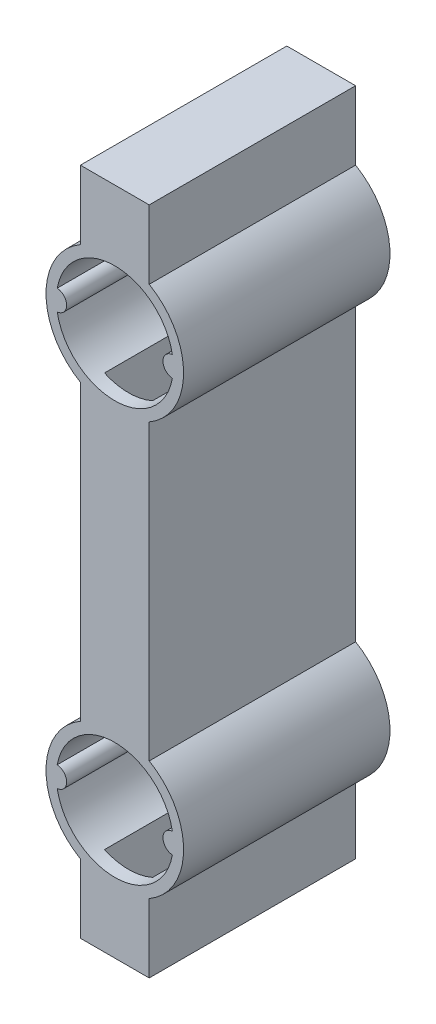
from build123d import *
from build123d.topology import SkipClean

# Parameters (mm, degrees)
BOSS_EXTRU_1_DEPTH      = 30
ENL_V_MAT_EXTRU_1_DEPTH = 28
BOSS_EXTRU_2_DEPTH      = 2
ESQUISSE5_R             = 2.5
ENL_V_MAT_EXTRU_2_DEPTH = 2
BOSS_EXTRU_3_DEPTH      = 29
ENL_V_MAT_EXTRU_4_DEPTH = 29
BOSS_EXTRU_4_DEPTH      = 28


with BuildPart() as part:
    # Esquisse1 → Boss.-Extru.1 (new body)
    with BuildSketch(Plane.XY):
        with BuildLine():
            Line((-5, -21.339745962), (-5, 21.339745962))
            ThreePointArc((-5, 21.339745962), (-10, 30), (-5, 38.660254038))
            Line((-5, 38.660254038), (-5, 48.660254038))
            Line((-5, 48.660254038), (5, 48.660254038))
            Line((5, 48.660254038), (5, 38.660254038))
            ThreePointArc((5, 38.660254038), (10, 30), (5, 21.339745962))
            Line((5, 21.339745962), (5, -21.339745962))
            ThreePointArc((5, -21.339745962), (10, -30), (5, -38.660254038))
            Line((5, -38.660254038), (5, -48.660254038))
            Line((5, -48.660254038), (-5, -48.660254038))
            Line((-5, -48.660254038), (-5, -38.660254038))
            ThreePointArc((-5, -38.660254038), (-10, -30), (-5, -21.339745962))
        make_face()
    extrude(amount=BOSS_EXTRU_1_DEPTH)

    # Esquisse2 → Enl_v. mat.-Extru.1 (cut)
    with BuildSketch(Plane.XY.offset(30)):
        with BuildLine():
            Line((-3.5, 22.254033308), (-3.5, -22.254033308))
            ThreePointArc((-3.5, -22.254033308), (-8.5, -30), (-3.5, -37.745966692))
            Line((-3.5, -37.745966692), (-3.5, -47.160254038))
            Line((-3.5, -47.160254038), (3.5, -47.160254038))
            Line((3.5, -47.160254038), (3.5, -37.745966692))
            ThreePointArc((3.5, -37.745966692), (8.5, -30), (3.5, -22.254033308))
            Line((3.5, -22.254033308), (3.5, 22.254033308))
            ThreePointArc((3.5, 22.254033308), (8.5, 30), (3.5, 37.745966692))
            Line((3.5, 37.745966692), (3.5, 47.160254038))
            Line((3.5, 47.160254038), (-3.5, 47.160254038))
            Line((-3.5, 47.160254038), (-3.5, 37.745966692))
            ThreePointArc((-3.5, 37.745966692), (-8.5, 30), (-3.5, 22.254033308))
        make_face()
    extrude(amount=-ENL_V_MAT_EXTRU_1_DEPTH, mode=Mode.SUBTRACT)

    # Esquisse3 → Boss.-Extru.2 (add)
    with SkipClean():  # keep this step's faces unmerged: merging them makes the solid invalid here
        with BuildSketch(Plane.XY.offset(30)):
            with BuildLine():
                Line((-3.5, 37.745966692), (-3.5, 47.160254038))
                Line((-3.5, 47.160254038), (3.5, 47.160254038))
                Line((3.5, 47.160254038), (3.5, 37.745966692))
                ThreePointArc((3.5, 37.745966692), (0, 38.5), (-3.5, 37.745966692))
            make_face()
            with BuildLine():
                Line((-3.5, -37.745966692), (-3.5, -47.160254038))
                Line((-3.5, -47.160254038), (3.5, -47.160254038))
                Line((3.5, -47.160254038), (3.5, -37.745966692))
                ThreePointArc((3.5, -37.745966692), (0, -38.5), (-3.5, -37.745966692))
            make_face()
            with BuildLine():
                Line((3.5, -22.254033308), (3.5, 22.254033308))
                ThreePointArc((3.5, 22.254033308), (0, 21.5), (-3.5, 22.254033308))
                Line((-3.5, 22.254033308), (-3.5, -22.254033308))
                ThreePointArc((-3.5, -22.254033308), (0, -21.5), (3.5, -22.254033308))
            make_face()
        extrude(amount=-BOSS_EXTRU_2_DEPTH)

    # Esquisse5 → Enl_v. mat.-Extru.2 (cut)
    with SkipClean():  # keep this step's faces unmerged: merging them makes the solid invalid here
        with BuildSketch(Plane(origin=(0, 0, 0), x_dir=(-1, 0, 0), z_dir=(0, 0, -1))):
            Circle(ESQUISSE5_R)
            with BuildLine():
                Line((2.5, 45.074057395), (-2.5, 45.074057395))
                ThreePointArc((-2.5, 45.074057395), (-3.5, 46.074057395), (-2.5, 47.074057395))
                Line((-2.5, 47.074057395), (2.5, 47.074057395))
                ThreePointArc((2.5, 47.074057395), (3.5, 46.074057395), (2.5, 45.074057395))
            make_face()
            with BuildLine():
                Line((2.5, -45.074057395), (-2.5, -45.074057395))
                ThreePointArc((-2.5, -45.074057395), (-3.5, -46.074057395), (-2.5, -47.074057395))
                Line((-2.5, -47.074057395), (2.5, -47.074057395))
                ThreePointArc((2.5, -47.074057395), (3.5, -46.074057395), (2.5, -45.074057395))
            make_face()
        extrude(amount=-ENL_V_MAT_EXTRU_2_DEPTH, mode=Mode.SUBTRACT)

    # Esquisse8 → Boss.-Extru.3 (add)
    with SkipClean():  # keep this step's faces unmerged: merging them makes the solid invalid here
        with BuildSketch(Plane.XY.offset(30)):
            with BuildLine():
                ThreePointArc((8.367647059, -28.50585051), (7, -30), (8.367647059, -31.49414949))
                ThreePointArc((8.367647059, -31.49414949), (0, -38.5), (-8.367647059, -31.49414949))
                ThreePointArc((-8.367647059, -31.49414949), (-7, -30), (-8.367647059, -28.50585051))
                ThreePointArc((-8.367647059, -28.50585051), (0, -21.5), (8.367647059, -28.50585051))
            make_face()
        extrude(amount=-BOSS_EXTRU_3_DEPTH)

    # Esquisse8_15 → Enl_v. mat.-Extru.4 (cut)
    with SkipClean():  # keep this step's faces unmerged: merging them makes the solid invalid here
        with BuildSketch(Plane.XY.offset(30)):
            with BuildLine():
                ThreePointArc((-3.5, -37.745966692), (0, -38.5), (3.5, -37.745966692))
                ThreePointArc((3.5, -37.745966692), (6.706829822, -35.221918588), (8.367647059, -31.49414949))
                ThreePointArc((8.367647059, -31.49414949), (7, -30), (8.367647059, -28.50585051))
                ThreePointArc((8.367647059, -28.50585051), (6.706829822, -24.778081412), (3.5, -22.254033308))
                ThreePointArc((3.5, -22.254033308), (0, -21.5), (-3.5, -22.254033308))
                ThreePointArc((-3.5, -22.254033308), (-6.706829822, -24.778081412), (-8.367647059, -28.50585051))
                ThreePointArc((-8.367647059, -28.50585051), (-7, -30), (-8.367647059, -31.49414949))
                ThreePointArc((-8.367647059, -31.49414949), (-6.706829822, -35.221918588), (-3.5, -37.745966692))
            make_face()
        extrude(amount=-ENL_V_MAT_EXTRU_4_DEPTH, mode=Mode.SUBTRACT)

    # Esquisse12 → Boss.-Extru.4 (add)
    with SkipClean():  # keep this step's faces unmerged: merging them makes the solid invalid here
        with BuildSketch(Plane.XY.offset(2)):
            with BuildLine():
                ThreePointArc((8.367647059, -31.49414949), (8.5, -30), (8.367647059, -28.50585051))
                ThreePointArc((8.367647059, -28.50585051), (7, -30), (8.367647059, -31.49414949))
            make_face()
            with BuildLine():
                ThreePointArc((-8.367647059, -31.49414949), (-7, -30), (-8.367647059, -28.50585051))
                ThreePointArc((-8.367647059, -28.50585051), (-8.5, -30), (-8.367647059, -31.49414949))
            make_face()
        boss_extru_4 = extrude(amount=BOSS_EXTRU_4_DEPTH)

    # Sym_trie1: Boss.-Extru.4 across plane
    with SkipClean():  # keep this step's faces unmerged: merging them makes the solid invalid here
        add(boss_extru_4.mirror(Plane.ZX))


solid = part.part
